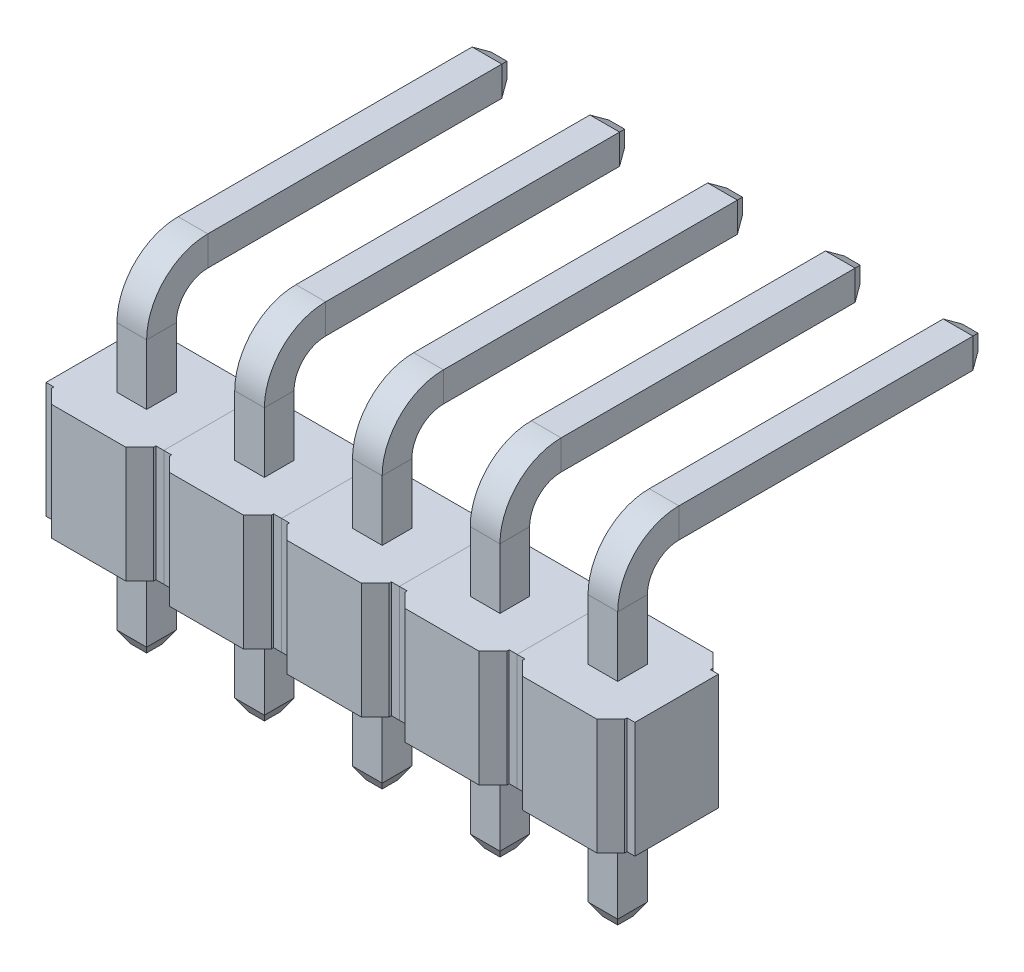
from build123d import *

# Parameters (mm, degrees)
SKETCH_3_W             = 0.64
SKETCH_3_H             = 0.64
CHAMFER_1_SIZE         = 0.15
CHAMFER_1_SIZE2        = 0.259807621
CHAMFER_1_PART_2_SIZE  = 0.15
CHAMFER_1_PART_2_SIZE2 = 0.259807621
EXTRUDE_1_DEPTH        = 2.5
CHAMFER_2_SIZE         = 0.3
PATTERN_LINEAR_1_COUNT = 5
PATTERN_LINEAR_1_PITCH = 2.54


with BuildPart() as part:
    # По траектории1: sweep along a path in Эскиз2
    with BuildLine(Plane(origin=(0, 0, 0), x_dir=(0, 0, -1), z_dir=(1, 0, 0))) as sweep_1_path:
        Line((0, -2.2), (0, 0))
        Line((0, 0), (0, 3.8))
        ThreePointArc((0, 3.8), (0.292893219, 4.507106781), (1, 4.8))
        Line((1, 4.8), (7.6, 4.8))
    # Эскиз3 → По траектории1 (sweep)
    with BuildSketch(Plane(origin=(0, 0, 0), x_dir=(1, 0, 0), z_dir=(0, 1, 0))):
        Rectangle(SKETCH_3_W, SKETCH_3_H)
    sweep(path=sweep_1_path.line)

    # Фаска1
    chamfer_1_edges = [part.edges().sort_by_distance(p)[0] for p in [
        (0, 4.48, -7.6),
        (-0.32, 4.8, -7.6),
        (0, 5.12, -7.6),
        (0.32, 4.8, -7.6),
    ]]
    chamfer_1_side = [part.faces().sort_by_distance(p)[0] for p in [
        (0, 4.8, -7.6),
    ]]
    chamfer(chamfer_1_edges, length=CHAMFER_1_SIZE, length2=CHAMFER_1_SIZE2, reference=chamfer_1_side[0])

    # Фаска1 part 2
    chamfer_1_part_2_edges = [part.edges().sort_by_distance(p)[0] for p in [
        (0.32, -2.2, 0),
        (0, -2.2, -0.32),
        (-0.32, -2.2, 0),
        (0, -2.2, 0.32),
    ]]
    chamfer_1_part_2_side = [part.faces().sort_by_distance(p)[0] for p in [
        (0, -2.2, 0),
    ]]
    chamfer(chamfer_1_part_2_edges, length=CHAMFER_1_PART_2_SIZE, length2=CHAMFER_1_PART_2_SIZE2, reference=chamfer_1_part_2_side[0])


with BuildPart() as body_2:
    # Эскиз4 → Бобышка-Вытянуть1 (new body)
    with BuildSketch(Plane(origin=(0, 0, 0), x_dir=(1, 0, 0), z_dir=(0, 1, 0))):
        Polygon((-1.1, 0.9), (-1.1, 1.25), (1.1, 1.25), (1.1, 0.9), (1.27, 0.9), (1.27, -0.9), (1.1, -0.9), (1.1, -1.25), (-1.1, -1.25), (-1.1, -0.9), (-1.27, -0.9), (-1.27, 0.9), align=None)
    extrude(amount=EXTRUDE_1_DEPTH)

    # Фаска2
    chamfer_2_edges = [body_2.edges().sort_by_distance(p)[0] for p in [
        (1.1, 1.25, 1.25),
        (-1.1, 1.25, 1.25),
        (-1.1, 1.25, -1.25),
        (1.1, 1.25, -1.25),
    ]]
    chamfer(chamfer_2_edges, length=CHAMFER_2_SIZE)


with BuildPart() as pattern_linear_1_1:
    # Линейный массив1: pattern copy
    add(body_2.part.moved(Location(Vector(-1, 0, 0) * (1 * PATTERN_LINEAR_1_PITCH))))


with BuildPart() as pattern_linear_1_2:
    # Линейный массив1: pattern copy
    add(body_2.part.moved(Location(Vector(-1, 0, 0) * (2 * PATTERN_LINEAR_1_PITCH))))


with BuildPart() as pattern_linear_1_3:
    # Линейный массив1: pattern copy
    add(body_2.part.moved(Location(Vector(-1, 0, 0) * (3 * PATTERN_LINEAR_1_PITCH))))


with BuildPart() as pattern_linear_1_4:
    # Линейный массив1: pattern copy
    add(body_2.part.moved(Location(Vector(-1, 0, 0) * (4 * PATTERN_LINEAR_1_PITCH))))


with BuildPart() as pattern_linear_1_5:
    # Линейный массив1: pattern copy
    add(part.part.moved(Location(Vector(-1, 0, 0) * (1 * PATTERN_LINEAR_1_PITCH))))


with BuildPart() as pattern_linear_1_6:
    # Линейный массив1: pattern copy
    add(part.part.moved(Location(Vector(-1, 0, 0) * (2 * PATTERN_LINEAR_1_PITCH))))


with BuildPart() as pattern_linear_1_7:
    # Линейный массив1: pattern copy
    add(part.part.moved(Location(Vector(-1, 0, 0) * (3 * PATTERN_LINEAR_1_PITCH))))


with BuildPart() as pattern_linear_1_8:
    # Линейный массив1: pattern copy
    add(part.part.moved(Location(Vector(-1, 0, 0) * (4 * PATTERN_LINEAR_1_PITCH))))


solid = Compound([part.part, body_2.part, pattern_linear_1_1.part, pattern_linear_1_2.part, pattern_linear_1_3.part, pattern_linear_1_4.part, pattern_linear_1_5.part, pattern_linear_1_6.part, pattern_linear_1_7.part, pattern_linear_1_8.part])
